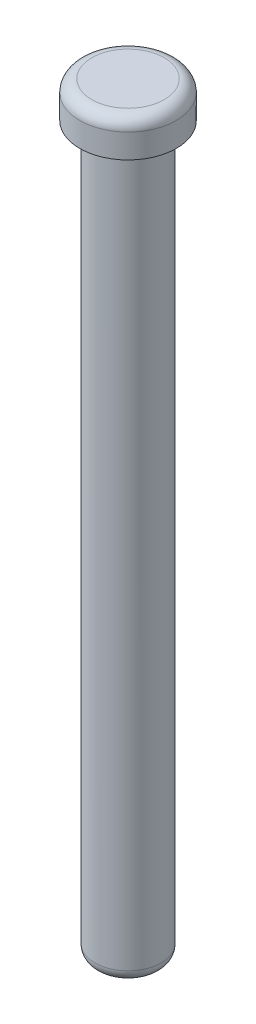
from build123d import *

# Parameters (mm, degrees)
FILLET1_R = 1


with BuildPart() as part:
    # Sketch1 → Revolve1 (revolve)
    with BuildSketch(Plane.XY):
        Polygon((0, 0), (0, 63), (-4, 63), (-4, 60), (-2.75, 60), (-2.75, 0), align=None)
    revolve(axis=Axis((0, 0, 0), (0, 1, 0)))

    # Fillet1
    fillet1_edges = [part.edges().sort_by_distance(p)[0] for p in [
        (2.75, 0, 0),
        (4, 63, 0),
    ]]
    fillet(fillet1_edges, radius=FILLET1_R)


solid = part.part
